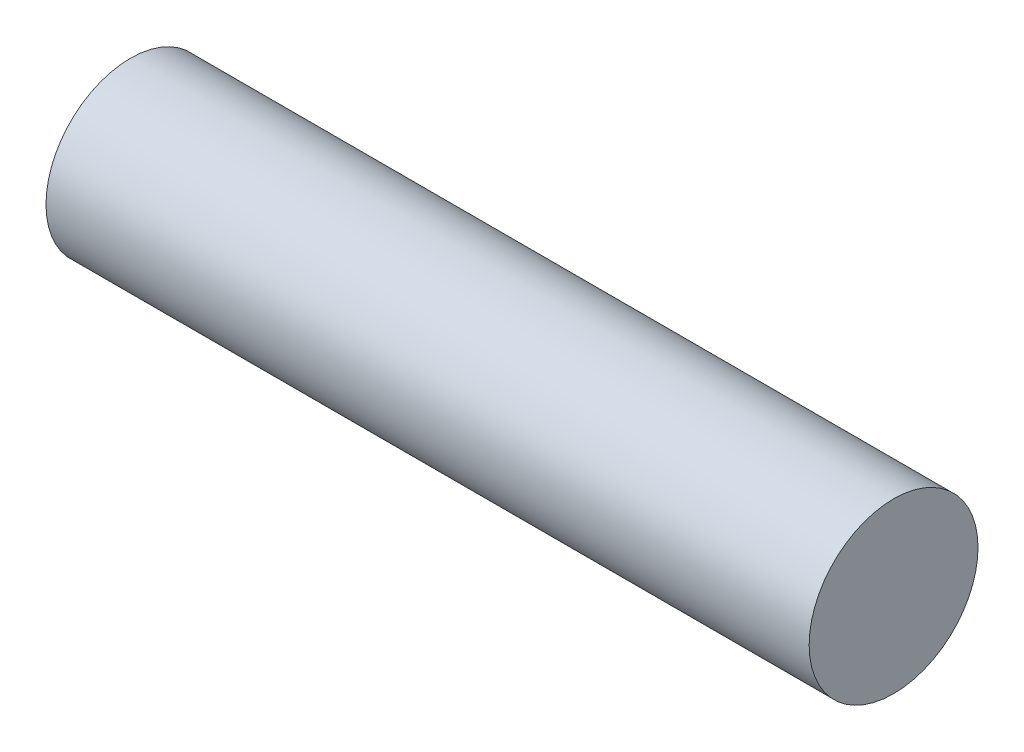
from build123d import *

# Parameters (mm, degrees)
SKETCH1_R  = 3.175
MAIN_DEPTH = 14.351


with BuildPart() as part:
    # Sketch1 → main (new body, symmetric)
    with BuildSketch(Plane(origin=(0, 0, 0), x_dir=(0, 0, -1), z_dir=(1, 0, 0))):
        Circle(SKETCH1_R)
    extrude(amount=MAIN_DEPTH, both=True)


solid = part.part
